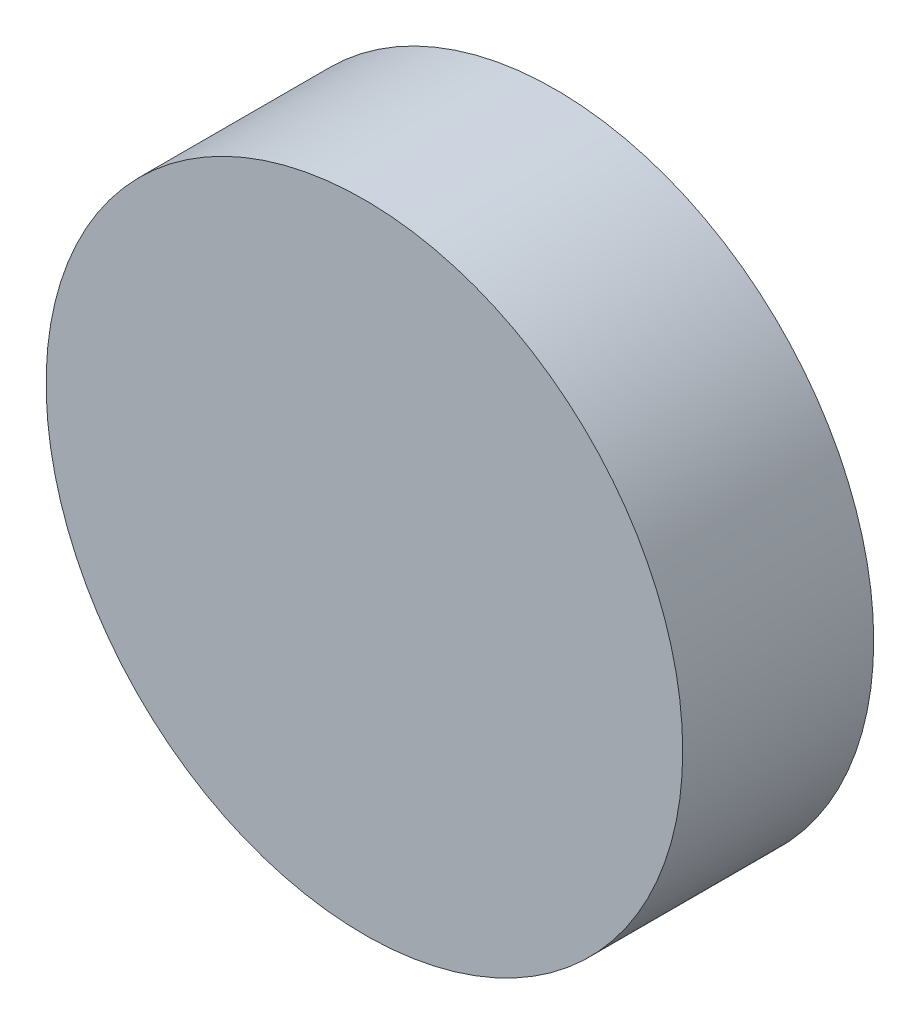
from build123d import *

# Parameters (mm, degrees)
SKETCH1_R           = 100
BOSS_EXTRUDE1_DEPTH = 60


with BuildPart() as part:
    # Sketch1 → Boss-Extrude1 (new body)
    with BuildSketch(Plane.XY):
        Circle(SKETCH1_R)
    extrude(amount=BOSS_EXTRUDE1_DEPTH)


solid = part.part
